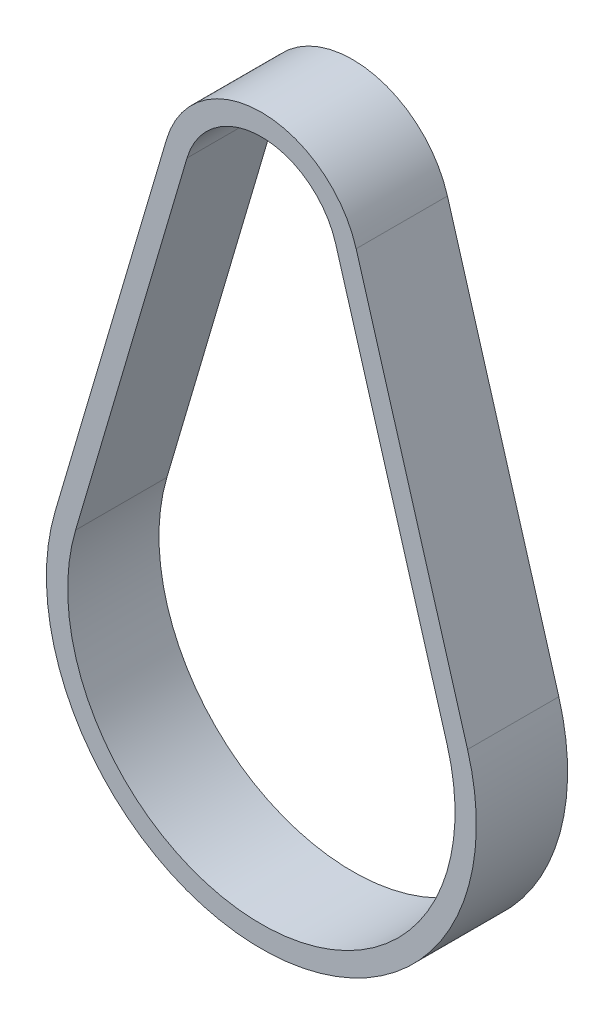
from build123d import *

# Parameters (mm, degrees)
EXTRUDE_THIN1_DEPTH = 6


with BuildPart() as part:
    # Sketch2 → Extrude-Thin1 (new body)
    with BuildSketch(Plane.XY):
        with BuildLine():
            Line((-6.178302498, 22.912219755), (1.145078416, -1.928771912))
            ThreePointArc((1.145078416, -1.928771912), (-12.408211999, -20.054421912), (-25.961502414, -1.928771912))
            Line((-25.961502414, -1.928771912), (-18.6381215, 22.912219755))
            ThreePointArc((-18.6381215, 22.912219755), (-12.408211999, 27.570578088), (-6.178302498, 22.912219755))
        make_face()
        with BuildLine():
            Line((-7.521162129, 22.516330866), (-0.197781214, -2.324660801))
            ThreePointArc((-0.197781214, -2.324660801), (-12.408211999, -18.654421912), (-24.618642783, -2.324660801))
            Line((-24.618642783, -2.324660801), (-17.295261869, 22.516330866))
            ThreePointArc((-17.295261869, 22.516330866), (-12.408211999, 26.170578088), (-7.521162129, 22.516330866))
        make_face(mode=Mode.SUBTRACT)
    extrude(amount=-EXTRUDE_THIN1_DEPTH)


solid = part.part
